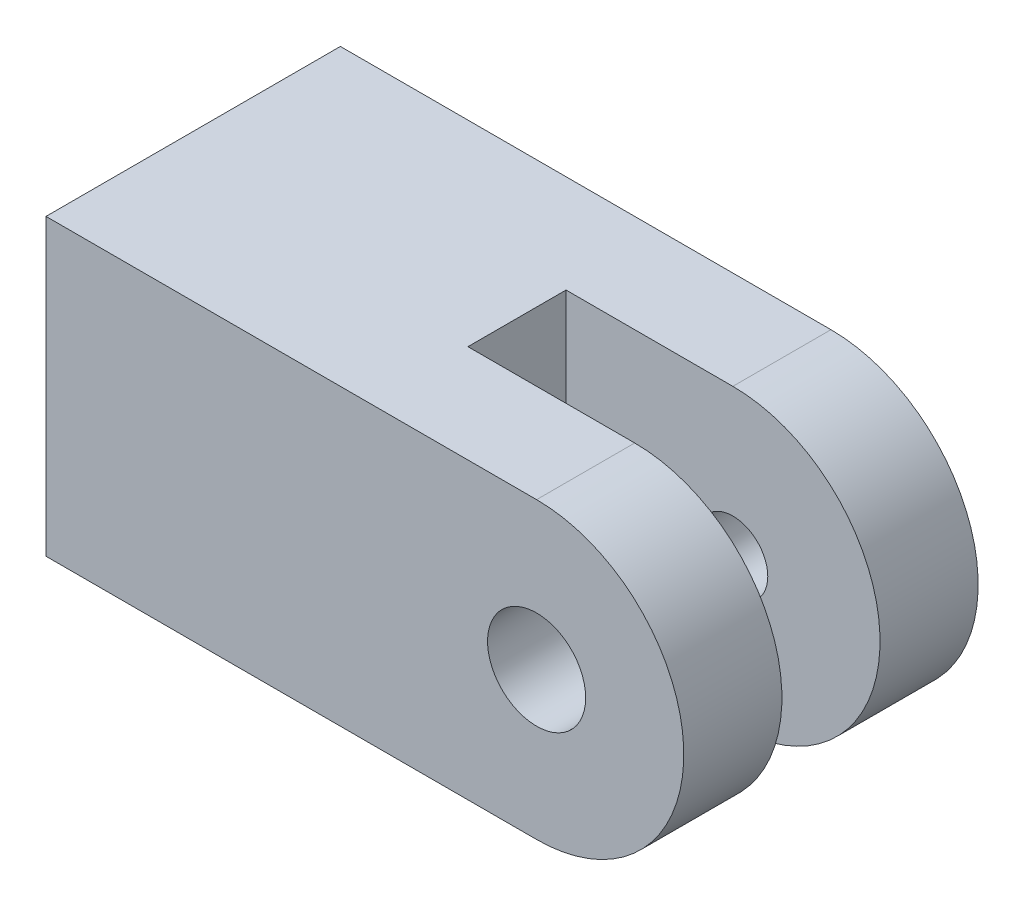
from build123d import *

# Parameters (mm, degrees)
BOSS_EXTRUDE2_DEPTH              = 4.7625
SKETCH3_W                        = 3.175
SKETCH3_H                        = 9.525
CUT_EXTRUDE1_DEPTH               = 10.16
SKETCH4_W                        = 9.525
SKETCH4_H                        = 9.525
BOSS_EXTRUDE3_DEPTH              = 6.35
F_8_32_TAPPED_HOLE1_D            = 3.4544
F_8_32_TAPPED_HOLE1_DEPTH        = 9.525
F_8_32_TAPPED_HOLE1_TIP          = 1.037806461
F_1_8_0_125_DIAMETER_HOLE1_D     = 3.175
F_1_8_0_125_DIAMETER_HOLE1_DEPTH = 3.175
F_4_40_TAPPED_HOLE1_D            = 2.2606


with BuildPart() as part:
    # Sketch2 → Boss-Extrude2 (new body, symmetric)
    with BuildSketch(Plane.XY):
        with BuildLine():
            Line((-9.525, 4.7625), (0, 4.7625))
            ThreePointArc((0, 4.7625), (4.7625, 0), (0, -4.7625))
            Line((0, -4.7625), (-9.525, -4.7625))
            Line((-9.525, -4.7625), (-9.525, 4.7625))
        make_face()
    extrude(amount=BOSS_EXTRUDE2_DEPTH, both=True)

    # Sketch3 → Cut-Extrude1 (cut)
    with BuildSketch(Plane(origin=(4.7625, 0, 0), x_dir=(0, 0, -1), z_dir=(1, 0, 0))):
        Rectangle(SKETCH3_W, SKETCH3_H)
    extrude(amount=-CUT_EXTRUDE1_DEPTH, mode=Mode.SUBTRACT)

    # Sketch4 → Boss-Extrude3 (add)
    with BuildSketch(Plane.ZY.offset(9.525)):
        Rectangle(SKETCH4_W, SKETCH4_H)
    extrude(amount=BOSS_EXTRUDE3_DEPTH)

    # #8-32 Tapped Hole1
    with Locations(Plane.ZY.offset(15.875)):
        with Locations((0, 0)):
            Hole(F_8_32_TAPPED_HOLE1_D / 2, depth=F_8_32_TAPPED_HOLE1_DEPTH)
            with Locations((0, 0, -(F_8_32_TAPPED_HOLE1_DEPTH + F_8_32_TAPPED_HOLE1_TIP / 2))):  # 118° drill point
                Cone(0, F_8_32_TAPPED_HOLE1_D / 2, F_8_32_TAPPED_HOLE1_TIP, mode=Mode.SUBTRACT)

    # 1/8 (0.125) Diameter Hole1
    with Locations(Plane.XY.offset(4.7625)):
        with Locations((0, 0)):
            Hole(F_1_8_0_125_DIAMETER_HOLE1_D / 2, depth=F_1_8_0_125_DIAMETER_HOLE1_DEPTH)

    # #4-40 Tapped Hole1 (through all)
    with Locations(Plane.XY.offset(-1.5875)):
        with Locations((0, 0)):
            Hole(F_4_40_TAPPED_HOLE1_D / 2)


solid = part.part
